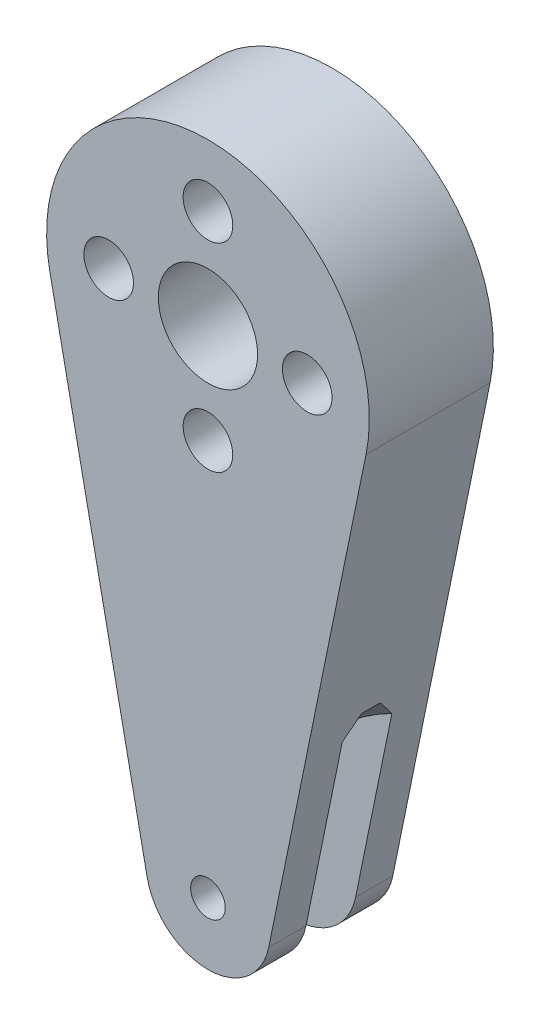
from build123d import *

# Parameters (mm, degrees)
SKETCH1_R                       = 4
SKETCH1_R_2                     = 2
SKETCH1_R_3                     = 1.395
BOSS_EXTRUDE1_DEPTH             = 5
SKETCH2_R                       = 5
BOSS_EXTRUDE2_DEPTH             = 2
BOSS_EXTRUDE3_REACH             = 7
SKETCH3_R                       = 19
BOSS_EXTRUDE3_DIRECTION_2_REACH = 7
CHAMFER1_SIZE                   = 1.25


with BuildPart() as part:
    # Sketch1 → Boss-Extrude1 (new body, symmetric)
    with BuildSketch(Plane.XY):
        with BuildLine():
            Line((4.898582231, -40.924328172), (12.736313801, -2.605054848))
            ThreePointArc((12.736313801, -2.605054848), (0, 13), (-12.736313801, -2.605054848))
            Line((-12.736313801, -2.605054848), (-4.898582231, -40.924328172))
            ThreePointArc((-4.898582231, -40.924328172), (0, -44.922384), (4.898582231, -40.924328172))
        make_face()
        Circle(SKETCH1_R, mode=Mode.SUBTRACT)
        with Locations((0, 8)):
            Circle(SKETCH1_R_2, mode=Mode.SUBTRACT)
        with Locations((8, 0)):
            Circle(SKETCH1_R_2, mode=Mode.SUBTRACT)
        with Locations((0, -8)):
            Circle(SKETCH1_R_2, mode=Mode.SUBTRACT)
        with Locations((-8, 0)):
            Circle(SKETCH1_R_2, mode=Mode.SUBTRACT)
        with Locations((0, -39.922384)):
            Circle(SKETCH1_R_3, mode=Mode.SUBTRACT)
    extrude(amount=BOSS_EXTRUDE1_DEPTH, both=True)


with BuildPart() as body_2:
    # Sketch2 → Boss-Extrude2 (new body, symmetric)
    with BuildSketch(Plane.XY):
        with Locations((0, -39.922384)):
            Circle(SKETCH2_R)
    extrude(amount=BOSS_EXTRUDE2_DEPTH, both=True)


with BuildPart() as part_1:
    add(part.part)

    # Combine1: cut body 2
    add(body_2.part, mode=Mode.SUBTRACT)


with BuildPart() as body_2_2:

    # Boss-Extrude3: up to this face of the body (flat: up to its plane)
    boss_extrude3_end = Plane(part_1.part.faces().sort_by_distance((0, -35.063805356, 2))[0])
    # Sketch3 → Boss-Extrude3 (new body, up to the picked face)
    with BuildSketch(Plane.XY, mode=Mode.PRIVATE) as boss_extrude3_sk1:
        with Locations((15.804791675, -42.49169824)):
            Circle(SKETCH3_R)
    boss_extrude3_tool1 = split(extrude(boss_extrude3_sk1.sketch, amount=BOSS_EXTRUDE3_REACH, mode=Mode.PRIVATE), bisect_by=boss_extrude3_end, keep=Keep.BOTH, mode=Mode.PRIVATE)
    add(boss_extrude3_tool1.solids().sort_by_distance((15.804792, -42.491698, 0))[0])


    # Boss-Extrude3 direction 2: up to this face of the body (flat: up to its plane)
    boss_extrude3_direction_2_end = Plane(part_1.part.faces().sort_by_distance((0, -35.063805356, -2))[0])
    # Sketch3 → Boss-Extrude3 direction 2 (add, up to the picked face)
    with BuildSketch(Plane.XY, mode=Mode.PRIVATE) as boss_extrude3_direction_2_sk1:
        with Locations((15.804791675, -42.49169824)):
            Circle(SKETCH3_R)
    boss_extrude3_direction_2_tool1 = split(extrude(boss_extrude3_direction_2_sk1.sketch, amount=-BOSS_EXTRUDE3_DIRECTION_2_REACH, mode=Mode.PRIVATE), bisect_by=boss_extrude3_direction_2_end, keep=Keep.BOTH, mode=Mode.PRIVATE)
    add(boss_extrude3_direction_2_tool1.solids().sort_by_distance((15.804792, -42.491698, 0))[0])

    # Chamfer1
    chamfer1_edges = [body_2_2.edges().sort_by_distance(p)[0] for p in [
        (-3.195208325, -42.49169824, -2),
        (-3.195208325, -42.49169824, 2),
    ]]
    chamfer(chamfer1_edges, length=CHAMFER1_SIZE)


with BuildPart() as part_2:
    add(part_1.part)

    # Combine2: cut body 2 2
    add(body_2_2.part, mode=Mode.SUBTRACT)


solid = part_2.part
